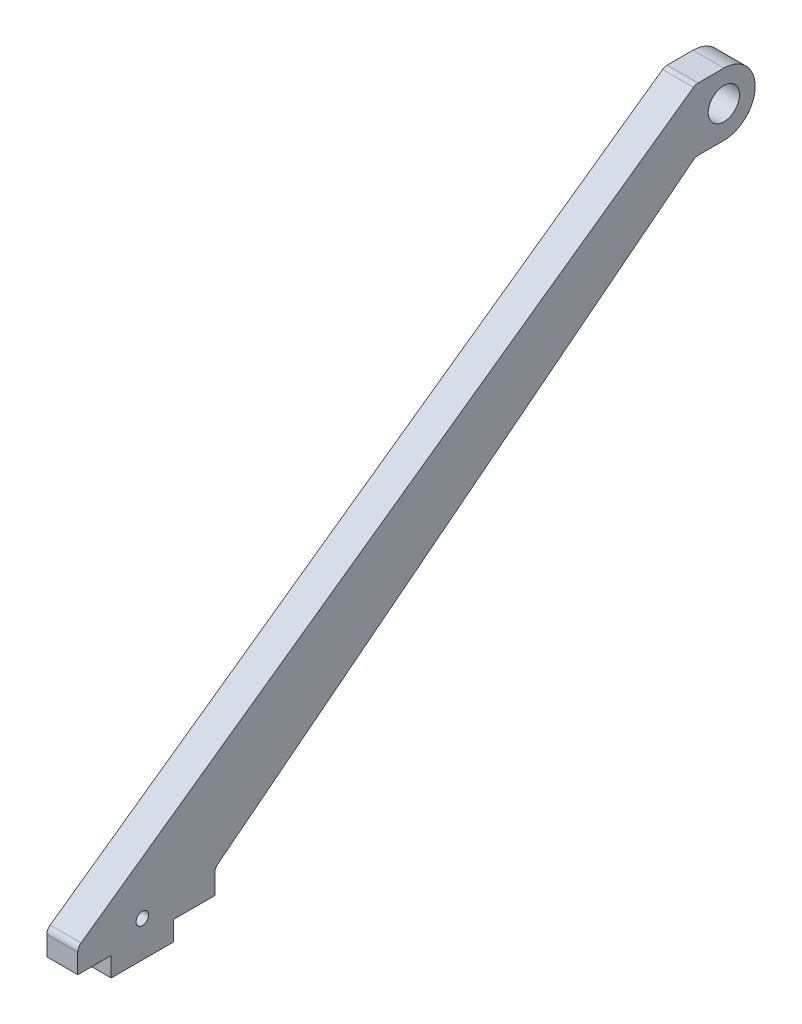
from build123d import *

# Parameters (mm, degrees)
BOSS_EXTRU_1_DEPTH      = 7.9
ESQUISSE2_R             = 1.6
ESQUISSE2_R_2           = 4
ENL_V_MAT_EXTRU_1_DEPTH = 8.9
CONG_1_R                = 2


with BuildPart() as part:
    # Esquisse1 → Boss.-Extru.1 (new body)
    with BuildSketch(Plane(origin=(0, 0, 0), x_dir=(0, 0, -1), z_dir=(1, 0, 0))):
        with BuildLine():
            Line((37.960924758, 1.984416578), (37.960924758, 6.984416578))
            Line((37.960924758, 6.984416578), (29.410924758, 6.984416578))
            Line((29.410924758, 6.984416578), (29.410924758, 12.984416578))
            Line((29.410924758, 12.984416578), (187.175507503, 124.984416578))
            Line((187.175507503, 124.984416578), (194.410924758, 124.984416578))
            ThreePointArc((194.410924758, 124.984416578), (202.410924758, 116.984416578), (194.410924758, 108.984416578))
            Line((194.410924758, 108.984416578), (187.175507503, 108.984416578))
            Line((187.175507503, 108.984416578), (64.410924758, 12.984416578))
            Line((64.410924758, 12.984416578), (64.410924758, 6.984416578))
            Line((64.410924758, 6.984416578), (53.860924758, 6.984416578))
            Line((53.860924758, 6.984416578), (53.860924758, 1.984416578))
            Line((53.860924758, 1.984416578), (37.960924758, 1.984416578))
        make_face()
    extrude(amount=BOSS_EXTRU_1_DEPTH)

    # Esquisse2 → Enlèv. mat.-Extru.1 (cut, through all)
    with BuildSketch(Plane(origin=(7.9, 0, 0), x_dir=(0, 0, -1), z_dir=(1, 0, 0))):
        with Locations((45.910924758, 11.184416578)):
            Circle(ESQUISSE2_R)
        with Locations((194.410924758, 117.118890011)):
            Circle(ESQUISSE2_R_2)
    extrude(amount=-ENL_V_MAT_EXTRU_1_DEPTH, mode=Mode.SUBTRACT)

    # Congé1
    cong_1_edges = [part.edges().sort_by_distance(p)[0] for p in [
        (3.95, 12.984416578, -64.410924758),
        (3.95, 108.984416578, -187.175507503),
        (3.95, 124.984416578, -187.175507503),
        (3.95, 12.984416578, -29.410924758),
    ]]
    fillet(cong_1_edges, radius=CONG_1_R)


solid = part.part
